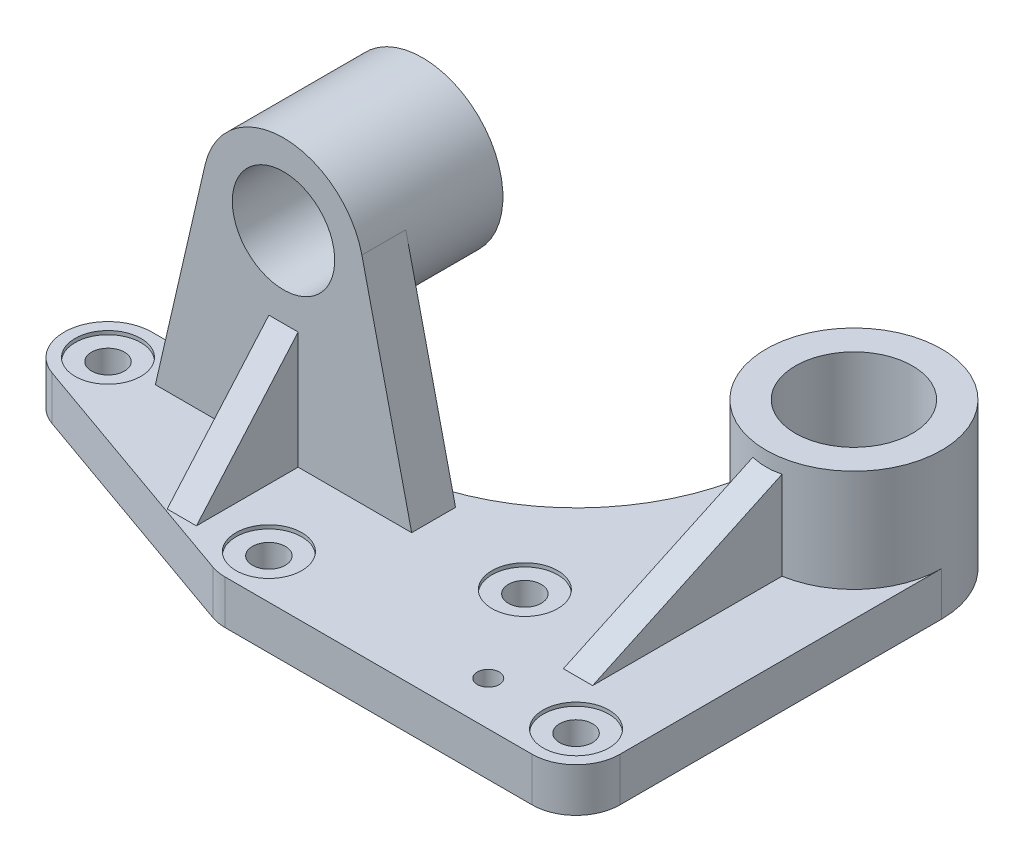
from build123d import *

# Parameters (mm, degrees)
SKETCH2_R           = 25.4
SKETCH2_R_2         = 4.7625
SKETCH2_R_3         = 7.14375
BOSS_EXTRUDE1_DEPTH = 17.4625
SKETCH2_4_R         = 25.4
SKETCH2_4_R_2       = 14.2875
SKETCH2_4_R_3       = 4.7625
BOSS_EXTRUDE2_DEPTH = 19.05
SKETCH2_5_R         = 25.4
BOSS_EXTRUDE3_DEPTH = 63.5
SKETCH4_R           = 22.225
BOSS_EXTRUDE4_DEPTH = 19.05
BOSS_EXTRUDE5_START = 41.275
SKETCH4_5_R         = 22.225
BOSS_EXTRUDE5_DEPTH = 41.275
RIB1_REACH          = 322.848
SKETCH5_WALL_W      = 733.847979228
SKETCH5_WALL_H      = 12.7
RIB2_REACH          = 282.408
SKETCH6_WALL_W      = 630.127475074
SKETCH6_WALL_H      = 12.7
RIB3_REACH          = 282.408
SKETCH7_WALL_W      = 618.773406406
SKETCH7_WALL_H      = 12.7


with BuildPart() as part:
    # Sketch2 → Boss-Extrude1 (new body)
    with BuildSketch(Plane(origin=(0, 0, 0), x_dir=(1, 0, 0), z_dir=(0, 1, 0))):
        with BuildLine():
            ThreePointArc((38.1, 0), (0.952797982, 38.088084436), (-38.052345197, 1.905))
            ThreePointArc((-38.052345197, 1.905), (-65.571053954, -58.064169637), (-126.841150657, -82.55))
            Line((-126.841150657, -82.55), (-222.25, -82.55))
            ThreePointArc((-222.25, -82.55), (-241.02652856, -98.383717171), (-228.590223243, -119.563965855))
            Line((-228.590223243, -119.563965855), (-120.640223243, -157.663965855))
            ThreePointArc((-120.640223243, -157.663965855), (-117.516282829, -158.47652856), (-114.3, -158.75))
            Line((-114.3, -158.75), (19.05, -158.75))
            ThreePointArc((19.05, -158.75), (32.520384182, -153.170384182), (38.1, -139.7))
            Line((38.1, -139.7), (38.1, 0))
        make_face()
        Circle(SKETCH2_R, mode=Mode.SUBTRACT)
        with Locations((-19.05, -139.7)):
            Circle(SKETCH2_R_2, mode=Mode.SUBTRACT)
        with Locations((-44.45, -98.425)):
            Circle(SKETCH2_R_3, mode=Mode.SUBTRACT)
        with Locations((-114.3, -139.7)):
            Circle(SKETCH2_R_3, mode=Mode.SUBTRACT)
        with Locations((-222.25, -101.6)):
            Circle(SKETCH2_R_3, mode=Mode.SUBTRACT)
        with Locations((19.05, -139.7)):
            Circle(SKETCH2_R_3, mode=Mode.SUBTRACT)
    extrude(amount=BOSS_EXTRUDE1_DEPTH)

    # Sketch2_4 → Boss-Extrude2 (add)
    with BuildSketch(Plane(origin=(0, 0, 0), x_dir=(1, 0, 0), z_dir=(0, 1, 0))):
        with BuildLine():
            ThreePointArc((38.1, 0), (0.952797982, 38.088084436), (-38.052345197, 1.905))
            ThreePointArc((-38.052345197, 1.905), (-65.571053954, -58.064169637), (-126.841150657, -82.55))
            Line((-126.841150657, -82.55), (-222.25, -82.55))
            ThreePointArc((-222.25, -82.55), (-241.02652856, -98.383717171), (-228.590223243, -119.563965855))
            Line((-228.590223243, -119.563965855), (-120.640223243, -157.663965855))
            ThreePointArc((-120.640223243, -157.663965855), (-117.516282829, -158.47652856), (-114.3, -158.75))
            Line((-114.3, -158.75), (19.05, -158.75))
            ThreePointArc((19.05, -158.75), (32.520384182, -153.170384182), (38.1, -139.7))
            Line((38.1, -139.7), (38.1, 0))
        make_face()
        Circle(SKETCH2_4_R, mode=Mode.SUBTRACT)
        with Locations((-44.45, -98.425)):
            Circle(SKETCH2_4_R_2, mode=Mode.SUBTRACT)
        with Locations((-114.3, -139.7)):
            Circle(SKETCH2_4_R_2, mode=Mode.SUBTRACT)
        with Locations((-222.25, -101.6)):
            Circle(SKETCH2_4_R_2, mode=Mode.SUBTRACT)
        with Locations((-19.05, -139.7)):
            Circle(SKETCH2_4_R_3, mode=Mode.SUBTRACT)
        with Locations((19.05, -139.7)):
            Circle(SKETCH2_4_R_2, mode=Mode.SUBTRACT)
    extrude(amount=BOSS_EXTRUDE2_DEPTH)

    # Sketch2_5 → Boss-Extrude3 (add)
    with BuildSketch(Plane(origin=(0, 0, 0), x_dir=(1, 0, 0), z_dir=(0, 1, 0))):
        with BuildLine():
            ThreePointArc((-38.052345197, 1.905), (-0.952797982, -38.088084436), (38.1, 0))
            ThreePointArc((38.1, 0), (0.952797982, 38.088084436), (-38.052345197, 1.905))
        make_face()
        Circle(SKETCH2_5_R, mode=Mode.SUBTRACT)
    extrude(amount=BOSS_EXTRUDE3_DEPTH)

    # Sketch4 → Boss-Extrude4 (add)
    with BuildSketch(Plane(origin=(0, 0, 82.55), x_dir=(-1, 0, 0), z_dir=(0, 0, -1))):
        with BuildLine():
            Line((201.684846649, 19.05), (180.079874513, 112.631415573))
            ThreePointArc((180.079874513, 112.631415573), (146.05, 139.7), (112.020125487, 112.631415573))
            Line((112.020125487, 112.631415573), (90.415153351, 19.05))
            Line((90.415153351, 19.05), (201.684846649, 19.05))
        make_face()
        with Locations((146.05, 104.775)):
            Circle(SKETCH4_R, mode=Mode.SUBTRACT)
    extrude(amount=-BOSS_EXTRUDE4_DEPTH)

    # Sketch4_5 → Boss-Extrude5 (add)
    with BuildSketch(Plane(origin=(0, 0, 82.55), x_dir=(-1, 0, 0), z_dir=(0, 0, -1)).offset(BOSS_EXTRUDE5_START)):
        with BuildLine():
            ThreePointArc((180.975, 104.775), (180.75049706, 108.728622241), (180.079874513, 112.631415573))
            ThreePointArc((180.079874513, 112.631415573), (146.05, 139.7), (112.020125487, 112.631415573))
            ThreePointArc((112.020125487, 112.631415573), (142.096377759, 70.07450294), (180.975, 104.775))
        make_face()
        with Locations((146.05, 104.775)):
            Circle(SKETCH4_5_R, mode=Mode.SUBTRACT)
    extrude(amount=-BOSS_EXTRUDE5_DEPTH)

    # Sketch5 wall → Rib1 (add, up to next)
    with BuildSketch(Plane(origin=(0, 38.1, 78.952856836), x_dir=(0, -0.422618261742, 0.906307787036), z_dir=(0, -0.906307787036, -0.422618261742)), mode=Mode.PRIVATE) as rib1_sk1:
        Rectangle(SKETCH5_WALL_W, SKETCH5_WALL_H)
    rib1_tool1 = extrude(rib1_sk1.sketch, amount=RIB1_REACH, mode=Mode.PRIVATE) - part.part
    add(rib1_tool1.solids().sort_by_distance((0, 38.1, 78.952856836))[0])

    # Sketch6 wall → Rib2 (add, up to next)
    with BuildSketch(Plane(origin=(-146.05, 44.45, 123.67988314), x_dir=(0, 0.754709580223, -0.65605902899), z_dir=(0, 0.65605902899, 0.754709580223)), mode=Mode.PRIVATE) as rib2_sk1:
        Rectangle(SKETCH6_WALL_W, SKETCH6_WALL_H)
    rib2_tool1 = extrude(rib2_sk1.sketch, amount=-RIB2_REACH, mode=Mode.PRIVATE) - part.part
    add(rib2_tool1.solids().sort_by_distance((-146.05, 44.45, 123.67988314))[0])

    # Sketch7 wall → Rib3 (add, up to next)
    with BuildSketch(Plane(origin=(-146.05, 44.45, 70.818630511), x_dir=(0, 0.907846577763, -0.41930250565), z_dir=(0, 0.41930250565, 0.907846577763)), mode=Mode.PRIVATE) as rib3_sk1:
        Rectangle(SKETCH7_WALL_W, SKETCH7_WALL_H)
    rib3_tool1 = extrude(rib3_sk1.sketch, amount=RIB3_REACH, mode=Mode.PRIVATE) - part.part
    add(rib3_tool1.solids().sort_by_distance((-146.05, 44.45, 70.818630511))[0])


solid = part.part
